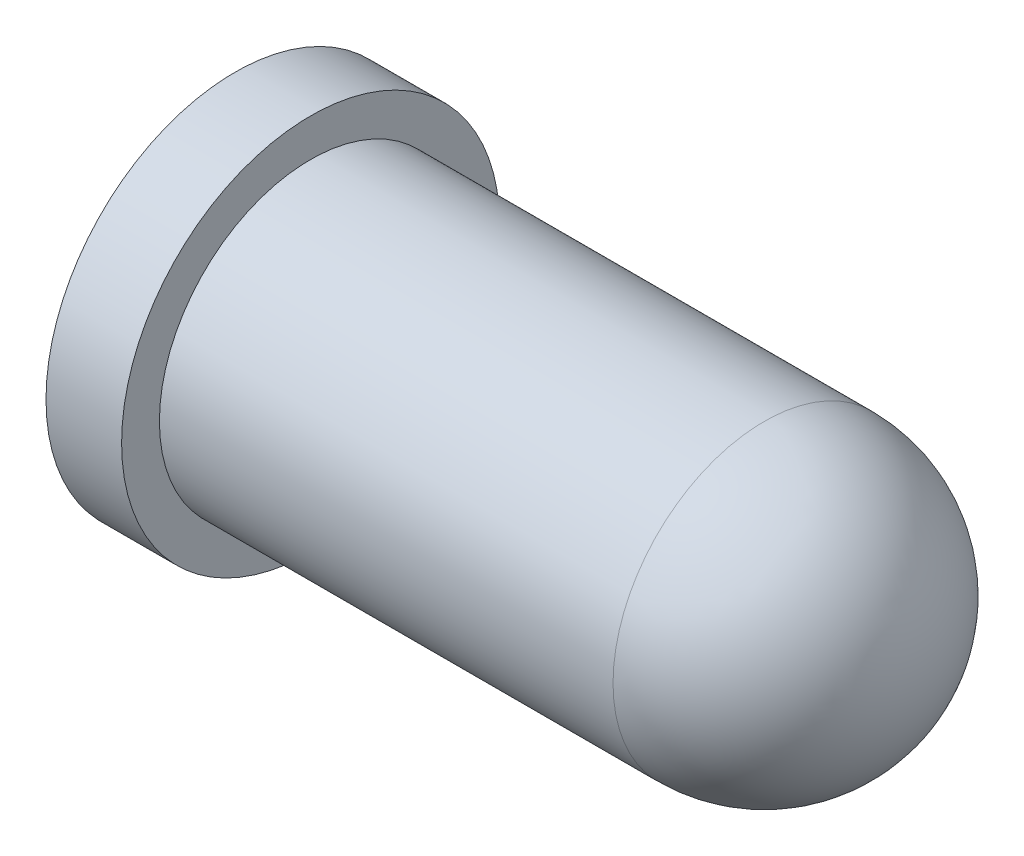
from build123d import *

# Parameters (mm, degrees)
SKETCH1_R           = 2.5
BOSS_EXTRUDE1_DEPTH = 1
SKETCH2_R           = 2
BOSS_EXTRUDE2_DEPTH = 8
FILLET2_R           = 2


with BuildPart() as part:
    # Sketch1 → Boss-Extrude1 (new body)
    with BuildSketch(Plane(origin=(0, 0, 0), x_dir=(0, 0, -1), z_dir=(1, 0, 0))):
        Circle(SKETCH1_R)
    extrude(amount=BOSS_EXTRUDE1_DEPTH)

    # Sketch2 → Boss-Extrude2 (add)
    with BuildSketch(Plane(origin=(1, 0, 0), x_dir=(0, 0, -1), z_dir=(1, 0, 0))):
        Circle(SKETCH2_R)
    extrude(amount=BOSS_EXTRUDE2_DEPTH)

    # Fillet2
    fillet2_edges = [part.edges().sort_by_distance(p)[0] for p in [
        (9, 0, 2),
    ]]
    fillet(fillet2_edges, radius=FILLET2_R)


solid = part.part
